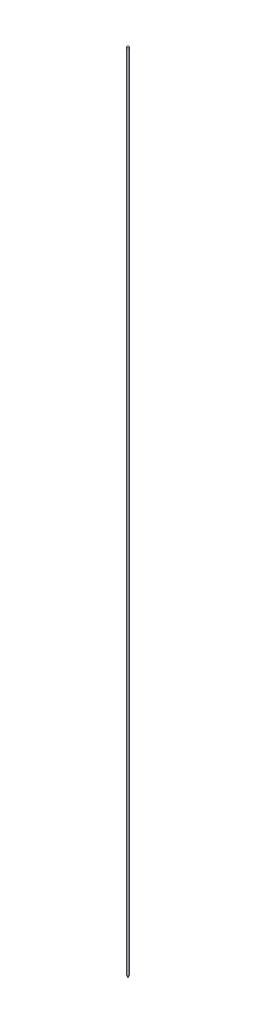
from build123d import *

# Parameters (mm, degrees)
REDONDEO1_R = 1


with BuildPart() as part:
    # Croquis1 → Revolución1 (revolve)
    with BuildSketch(Plane.XY):
        Polygon((0, 138.167565896), (1.5875, 138.167565896), (1.5875, -987.252434104), (0, -990.956527655), align=None)
    revolve(axis=Axis((0, 11.283751348, 0), (0, -1, 0)))

    # Redondeo1
    redondeo1_edges = [part.edges().sort_by_distance(p)[0] for p in [
        (-1.5875, -987.252434104, 0),
    ]]
    fillet(redondeo1_edges, radius=REDONDEO1_R)


solid = part.part
